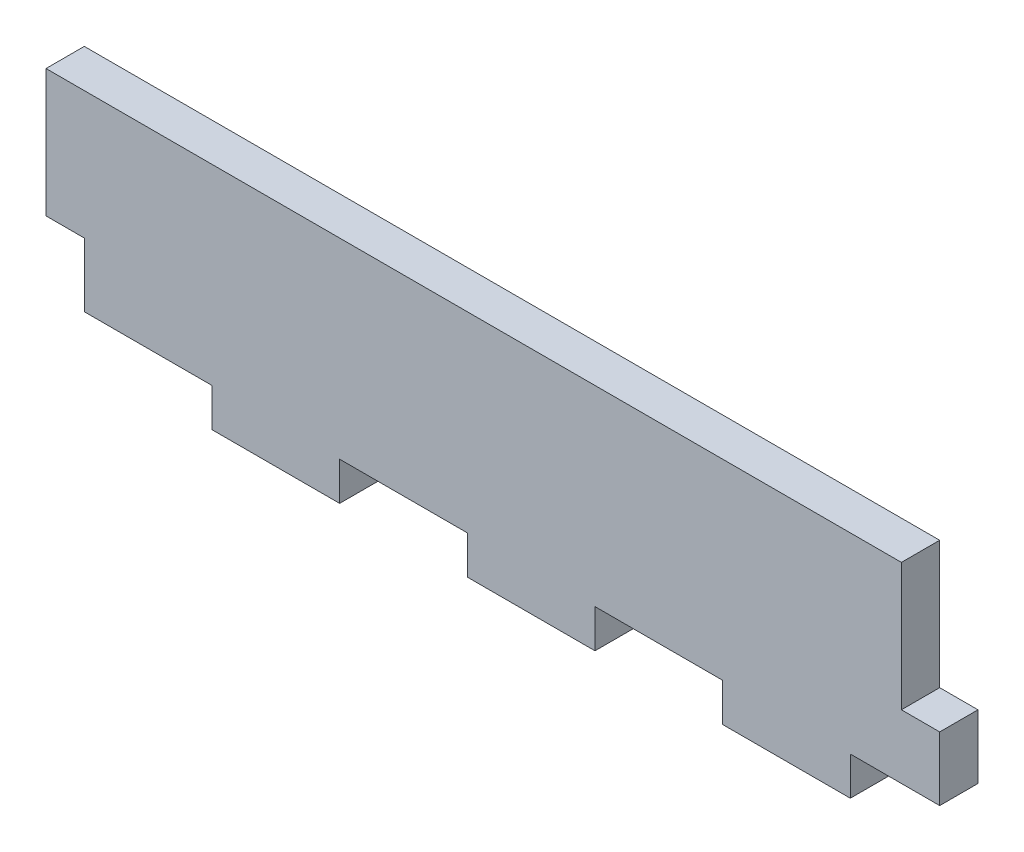
from build123d import *

# Parameters (mm, degrees)
ESQUISSE1_W                = 67
ESQUISSE1_H                = 18
BOSS_EXTRU_1_DEPTH         = 3
ESQUISSE2_W                = 10
ESQUISSE2_H                = 3
ENL_V_MAT_EXTRU_1_DEPTH    = 10
R_P_TITION_LIN_AIRE1_COUNT = 4
R_P_TITION_LIN_AIRE1_PITCH = 20
ESQUISSE3_W                = 3
ESQUISSE3_H                = 10
ENL_V_MAT_EXTRU_2_DEPTH    = 10
ESQUISSE4_W                = 3
ESQUISSE4_H                = 10
BOSS_EXTRU_2_DEPTH         = 3


with BuildPart() as part:
    # Esquisse1 → Boss.-Extru.1 (new body)
    with BuildSketch(Plane.XY):
        with Locations((33.5, -9)):
            Rectangle(ESQUISSE1_W, ESQUISSE1_H)
    extrude(amount=BOSS_EXTRU_1_DEPTH)

    # Esquisse2 → Enlèv. mat.-Extru.1 (cut)
    with BuildSketch(Plane.XY.offset(3)):
        with Locations((5, -16.5)):
            Rectangle(ESQUISSE2_W, ESQUISSE2_H)
    enl_v_mat_extru_1 = extrude(amount=-ENL_V_MAT_EXTRU_1_DEPTH, mode=Mode.SUBTRACT)

    # Répétition linéaire1: Enlèv. mat.-Extru.1 ×4
    with Locations(*[(i * R_P_TITION_LIN_AIRE1_PITCH, 0, 0) for i in range(1, R_P_TITION_LIN_AIRE1_COUNT)]):
        add(enl_v_mat_extru_1, mode=Mode.SUBTRACT)

    # Esquisse3 → Enlèv. mat.-Extru.2 (cut)
    with BuildSketch(Plane.XY.offset(3)):
        with Locations((65.5, -5)):
            Rectangle(ESQUISSE3_W, ESQUISSE3_H)
    extrude(amount=-ENL_V_MAT_EXTRU_2_DEPTH, mode=Mode.SUBTRACT)

    # Esquisse4 → Boss.-Extru.2 (add)
    with BuildSketch(Plane.ZY):
        with Locations((1.5, -5)):
            Rectangle(ESQUISSE4_W, ESQUISSE4_H)
    extrude(amount=BOSS_EXTRU_2_DEPTH)


solid = part.part
